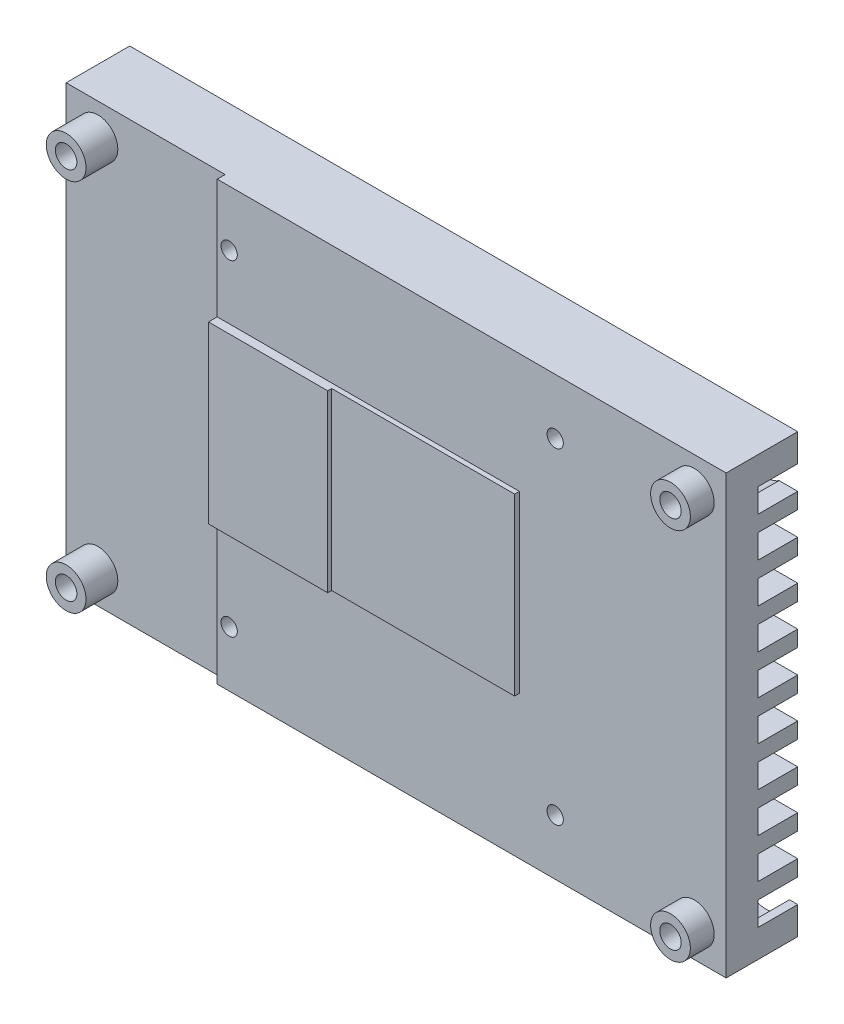
from build123d import *

# Parameters (mm, degrees)
SKETCH1_W                  = 84
SKETCH1_H                  = 55
EXTRUDE1_DEPTH             = 7
F_2_7_2_7_DIAMETER_HOLE1_D = 2.7
SKETCH6_OUTSIDE_W          = 106.13
SKETCH6_OUTSIDE_H          = 77.13
SKETCH6_OUTSIDE_R          = 2.5
EXTRUDE2_DEPTH             = 3
SKETCH7_W                  = 15
SKETCH7_H                  = 22
EXTRUDE3_DEPTH             = 1.1
SKETCH8_W                  = 26.471562954
SKETCH8_H                  = 62.575334395
SKETCH8_R                  = 2.5
EXTRUDE6_DEPTH             = 1
SKETCH9_W                  = 23
SKETCH9_H                  = 22
EXTRUDE7_DEPTH             = 0.6
M2_5X0_45_TAPPED_HOLE1_D   = 2.05
SKETCH14_W                 = 84
SKETCH14_H                 = 55
SKETCH14_R                 = 3
EXTRUDE12_DEPTH            = 5
SKETCH16_W                 = 105.280390668
SKETCH16_H                 = 3
EXTRUDE13_DEPTH            = 5


with BuildPart() as part:
    # Sketch1 → Extrude1 (new body)
    with BuildSketch(Plane.XY):
        Rectangle(SKETCH1_W, SKETCH1_H)
    extrude(amount=EXTRUDE1_DEPTH)

    # Ø2.7 (2.7) Diameter Hole1 (through all)
    with Locations(Plane.XY.offset(7)):
        with Locations((-38, 23.5), (38, 23.5), (38, -23.5), (-38, -23.5)):
            Hole(F_2_7_2_7_DIAMETER_HOLE1_D / 2)

    # Sketch6 outside → Extrude2 (cut)
    with BuildSketch(Plane.XY.offset(7)):
        Rectangle(SKETCH6_OUTSIDE_W, SKETCH6_OUTSIDE_H)
        with Locations((-38, 23.5)):
            Circle(SKETCH6_OUTSIDE_R, mode=Mode.SUBTRACT)
        with Locations((-38, -23.5)):
            Circle(SKETCH6_OUTSIDE_R, mode=Mode.SUBTRACT)
        with Locations((38, 23.5)):
            Circle(SKETCH6_OUTSIDE_R, mode=Mode.SUBTRACT)
        with Locations((38, -23.5)):
            Circle(SKETCH6_OUTSIDE_R, mode=Mode.SUBTRACT)
    extrude(amount=-EXTRUDE2_DEPTH, mode=Mode.SUBTRACT)

    # Sketch7 → Extrude3 (add)
    with BuildSketch(Plane.XY.offset(4)):
        with Locations((-14.5, 1.5)):
            Rectangle(SKETCH7_W, SKETCH7_H)
    extrude(amount=EXTRUDE3_DEPTH)

    # Sketch8 → Extrude6 (cut)
    with BuildSketch(Plane.XY.offset(4)):
        with Locations((-35.235781477, -1.105270853)):
            Rectangle(SKETCH8_W, SKETCH8_H)
        with Locations((-38, -23.5)):
            Circle(SKETCH8_R, mode=Mode.SUBTRACT)
        with Locations((-38, 23.5)):
            Circle(SKETCH8_R, mode=Mode.SUBTRACT)
    extrude(amount=-EXTRUDE6_DEPTH, mode=Mode.SUBTRACT)

    # Sketch9 → Extrude7 (add)
    with BuildSketch(Plane.XY.offset(4)):
        with Locations((4.5, 1.5)):
            Rectangle(SKETCH9_W, SKETCH9_H)
    extrude(amount=EXTRUDE7_DEPTH)

    # M2.5x0.45 Tapped Hole1 (through all)
    with Locations(Plane.XY.offset(7)):
        with Locations((-20.5, 20.5), (20.5, 20.5), (20.5, -20.5), (-20.5, -20.5)):
            Hole(M2_5X0_45_TAPPED_HOLE1_D / 2)

    # Sketch14 → Extrude12 (add)
    with BuildSketch(Plane(origin=(0, 0, 0), x_dir=(-1, 0, 0), z_dir=(0, 0, -1))):
        Rectangle(SKETCH14_W, SKETCH14_H)
        with Locations((-38, 23.5)):
            Circle(SKETCH14_R, mode=Mode.SUBTRACT)
        with Locations((-20.5, 20.5)):
            Circle(SKETCH14_R, mode=Mode.SUBTRACT)
        with Locations((20.5, 20.5)):
            Circle(SKETCH14_R, mode=Mode.SUBTRACT)
        with Locations((38, 23.5)):
            Circle(SKETCH14_R, mode=Mode.SUBTRACT)
        with Locations((-38, -23.5)):
            Circle(SKETCH14_R, mode=Mode.SUBTRACT)
        with Locations((-20.5, -20.5)):
            Circle(SKETCH14_R, mode=Mode.SUBTRACT)
        with Locations((20.5, -20.5)):
            Circle(SKETCH14_R, mode=Mode.SUBTRACT)
        with Locations((38, -23.5)):
            Circle(SKETCH14_R, mode=Mode.SUBTRACT)
    extrude(amount=EXTRUDE12_DEPTH)

    # Sketch16 → Extrude13 (cut)
    with BuildSketch(Plane(origin=(0, 0, -5), x_dir=(-1, 0, 0), z_dir=(0, 0, -1))):
        with Locations((-1.715862013, -22.499)):
            Rectangle(SKETCH16_W, SKETCH16_H)
        with Locations((-1.715862013, -17.499)):
            Rectangle(SKETCH16_W, SKETCH16_H)
        with Locations((-1.715862013, -12.499)):
            Rectangle(SKETCH16_W, SKETCH16_H)
        with Locations((-1.715862013, -7.499)):
            Rectangle(SKETCH16_W, SKETCH16_H)
        with Locations((-1.715862013, -2.499)):
            Rectangle(SKETCH16_W, SKETCH16_H)
        with Locations((-1.715862013, 2.501)):
            Rectangle(SKETCH16_W, SKETCH16_H)
        with Locations((-1.715862013, 7.501)):
            Rectangle(SKETCH16_W, SKETCH16_H)
        with Locations((-1.715862013, 12.501)):
            Rectangle(SKETCH16_W, SKETCH16_H)
        with Locations((-1.715862013, 17.501)):
            Rectangle(SKETCH16_W, SKETCH16_H)
        with Locations((-1.715862013, 22.501)):
            Rectangle(SKETCH16_W, SKETCH16_H)
    extrude(amount=-EXTRUDE13_DEPTH, mode=Mode.SUBTRACT)


solid = part.part
